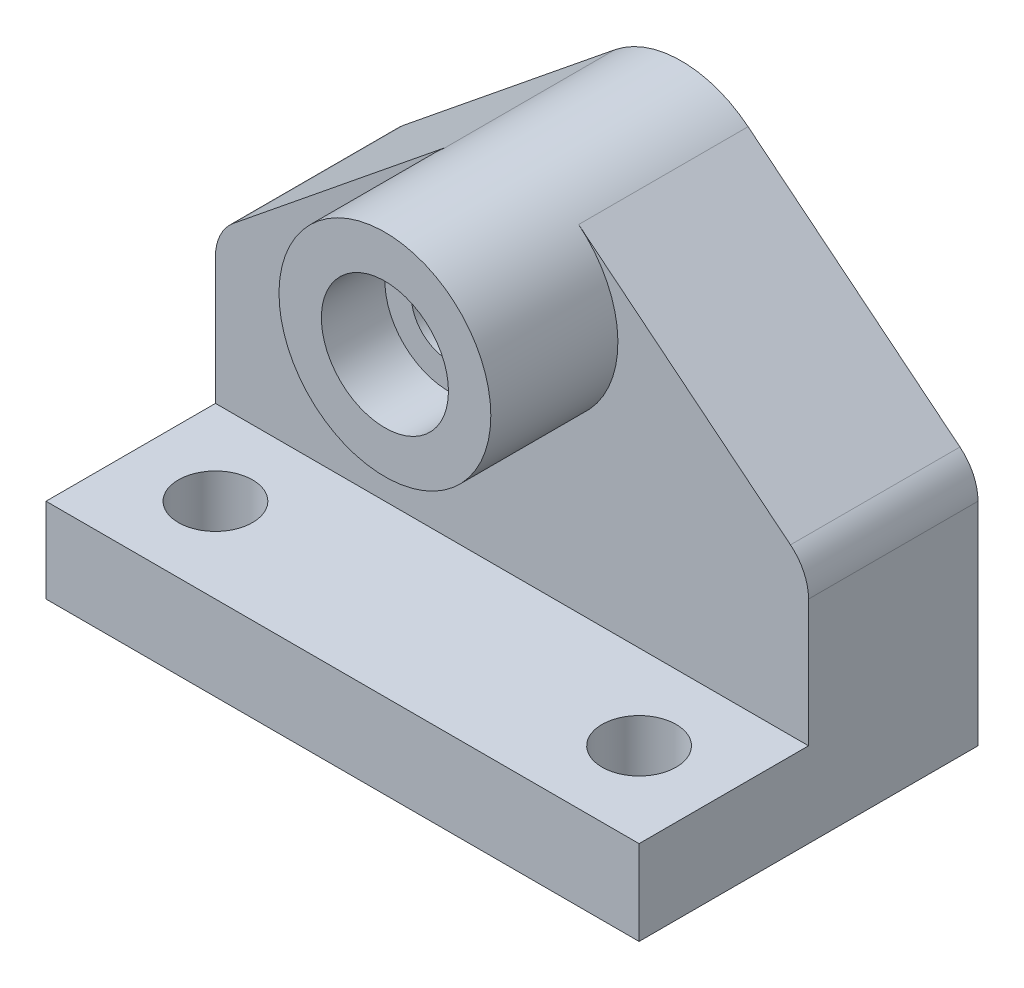
from build123d import *

# Parameters (mm, degrees)
BOSS_EXTRUDE1_DEPTH    = 80
SKETCH2_R              = 25
BOSS_EXTRUDE2_DEPTH    = 40
CUT_EXTRUDE2_DEPTH     = 40
M20_TAPPED_HOLE2_D     = 17.5
M20_TAPPED_HOLE2_DEPTH = 30
M20_TAPPED_HOLE2_TIP   = 5.257530416
SKETCH9_W              = 140
SKETCH9_H              = 40
CUT_EXTRUDE3_DEPTH     = 110
M20_TAPPED_HOLE3_D     = 17.5
M20_TAPPED_HOLE3_DEPTH = 37.5
M20_TAPPED_HOLE3_TIP   = 5.257530416
SKETCH14_R             = 25
SKETCH14_R_2           = 15
BOSS_EXTRUDE3_DEPTH    = 30
SKETCH15_R             = 15
BOSS_EXTRUDE4_DEPTH    = 30
SKETCH16_R             = 15
CUT_EXTRUDE4_DEPTH     = 15
M20_TAPPED_HOLE4_D     = 17.5
M20_TAPPED_HOLE4_DEPTH = 60
M20_TAPPED_HOLE4_TIP   = 5.257530416


with BuildPart() as part:
    # Sketch1 → Boss-Extrude1 (new body)
    with BuildSketch(Plane.XY):
        with BuildLine():
            Line((54.268808187, 99.430121053), (4.268808187, 58.948665044))
            ThreePointArc((4.268808187, 58.948665044), (1.121855986, 54.957351344), (0, 50))
            Line((0, 50), (0, 0))
            Line((0, 0), (140, 0))
            Line((140, 0), (140, 50))
            ThreePointArc((140, 50), (138.878144014, 54.957351344), (135.731191813, 58.948665044))
            Line((135.731191813, 58.948665044), (85.731191813, 99.430121053))
            ThreePointArc((85.731191813, 99.430121053), (92.56412856, 90.763833069), (95, 80))
            ThreePointArc((95, 80), (59.236166931, 57.43587144), (54.268808187, 99.430121053))
        make_face()
    extrude(amount=BOSS_EXTRUDE1_DEPTH)

    # Sketch2 → Boss-Extrude2 (add)
    with BuildSketch(Plane(origin=(0, 0, 0), x_dir=(-1, 0, 0), z_dir=(0, 0, -1))):
        with Locations((-70, 80)):
            Circle(SKETCH2_R)
    extrude(amount=-BOSS_EXTRUDE2_DEPTH)

    # Sketch3 → Cut-Extrude2 (cut)
    with BuildSketch(Plane.XY.offset(80)):
        with BuildLine():
            ThreePointArc((54.268808187, 99.430121053), (47.43587144, 90.763833069), (45, 80))
            Line((45, 80), (95, 80))
            ThreePointArc((95, 80), (92.56412856, 90.763833069), (85.731191813, 99.430121053))
            Line((85.731191813, 99.430121053), (95, 91.925824036))
            Line((95, 91.925824036), (95, 118.127818218))
            Line((95, 118.127818218), (45, 118.127818218))
            Line((45, 118.127818218), (45, 91.925824036))
            Line((45, 91.925824036), (54.268808187, 99.430121053))
        make_face()
        with BuildLine():
            Line((45, 91.925824036), (45, 80))
            ThreePointArc((45, 80), (47.43587144, 90.763833069), (54.268808187, 99.430121053))
            Line((54.268808187, 99.430121053), (45, 91.925824036))
        make_face()
        with BuildLine():
            ThreePointArc((85.731191813, 99.430121053), (92.56412856, 90.763833069), (95, 80))
            Line((95, 80), (95, 91.925824036))
            Line((95, 91.925824036), (85.731191813, 99.430121053))
        make_face()
    extrude(amount=-CUT_EXTRUDE2_DEPTH, mode=Mode.SUBTRACT)

    # M20 Tapped Hole2
    with Locations(Plane(origin=(20, 0, 20), x_dir=(0, 0, -1), z_dir=(0, -1, 0))):
        with Locations((0, 0), (0, 100)):
            Hole(M20_TAPPED_HOLE2_D / 2, depth=M20_TAPPED_HOLE2_DEPTH)
            with Locations((0, 0, -(M20_TAPPED_HOLE2_DEPTH + M20_TAPPED_HOLE2_TIP / 2))):  # 118° drill point
                Cone(0, M20_TAPPED_HOLE2_D / 2, M20_TAPPED_HOLE2_TIP, mode=Mode.SUBTRACT)

    # Sketch9 → Cut-Extrude3 (cut)
    with BuildSketch(Plane(origin=(0, 20, 0), x_dir=(1, 0, 0), z_dir=(0, 1, 0))):
        with Locations((70, -60)):
            Rectangle(SKETCH9_W, SKETCH9_H)
    extrude(amount=CUT_EXTRUDE3_DEPTH, mode=Mode.SUBTRACT)

    # M20 Tapped Hole3
    with Locations(Plane(origin=(20, 20, 60), x_dir=(0, 0, 1), z_dir=(0, 1, 0))):
        with Locations((0, 0), (0, 100)):
            Hole(M20_TAPPED_HOLE3_D / 2, depth=M20_TAPPED_HOLE3_DEPTH)
            with Locations((0, 0, -(M20_TAPPED_HOLE3_DEPTH + M20_TAPPED_HOLE3_TIP / 2))):  # 118° drill point
                Cone(0, M20_TAPPED_HOLE3_D / 2, M20_TAPPED_HOLE3_TIP, mode=Mode.SUBTRACT)

    # Sketch14 → Boss-Extrude3 (add)
    with BuildSketch(Plane.XY.offset(40)):
        with Locations(Location((70, 80, 0), (0, 0, 128.994638965))):
            Circle(SKETCH14_R)
        with Locations((70, 80)):
            Circle(SKETCH14_R_2, mode=Mode.SUBTRACT)
    extrude(amount=BOSS_EXTRUDE3_DEPTH)

    # Sketch15 → Boss-Extrude4 (add)
    with BuildSketch(Plane.XY.offset(40)):
        with Locations((70, 80)):
            Circle(SKETCH15_R)
    extrude(amount=BOSS_EXTRUDE4_DEPTH)

    # Sketch16 → Cut-Extrude4 (cut)
    with BuildSketch(Plane.XY.offset(70)):
        with Locations((70, 80)):
            Circle(SKETCH16_R)
    extrude(amount=-CUT_EXTRUDE4_DEPTH, mode=Mode.SUBTRACT)

    # M20 Tapped Hole4
    with Locations(Plane(origin=(70, 80, 55), x_dir=(1, 0, 0), z_dir=(0, 0, 1))):
        with Locations((0, 0)):
            Hole(M20_TAPPED_HOLE4_D / 2, depth=M20_TAPPED_HOLE4_DEPTH)
            with Locations((0, 0, -(M20_TAPPED_HOLE4_DEPTH + M20_TAPPED_HOLE4_TIP / 2))):  # 118° drill point
                Cone(0, M20_TAPPED_HOLE4_D / 2, M20_TAPPED_HOLE4_TIP, mode=Mode.SUBTRACT)


solid = part.part
